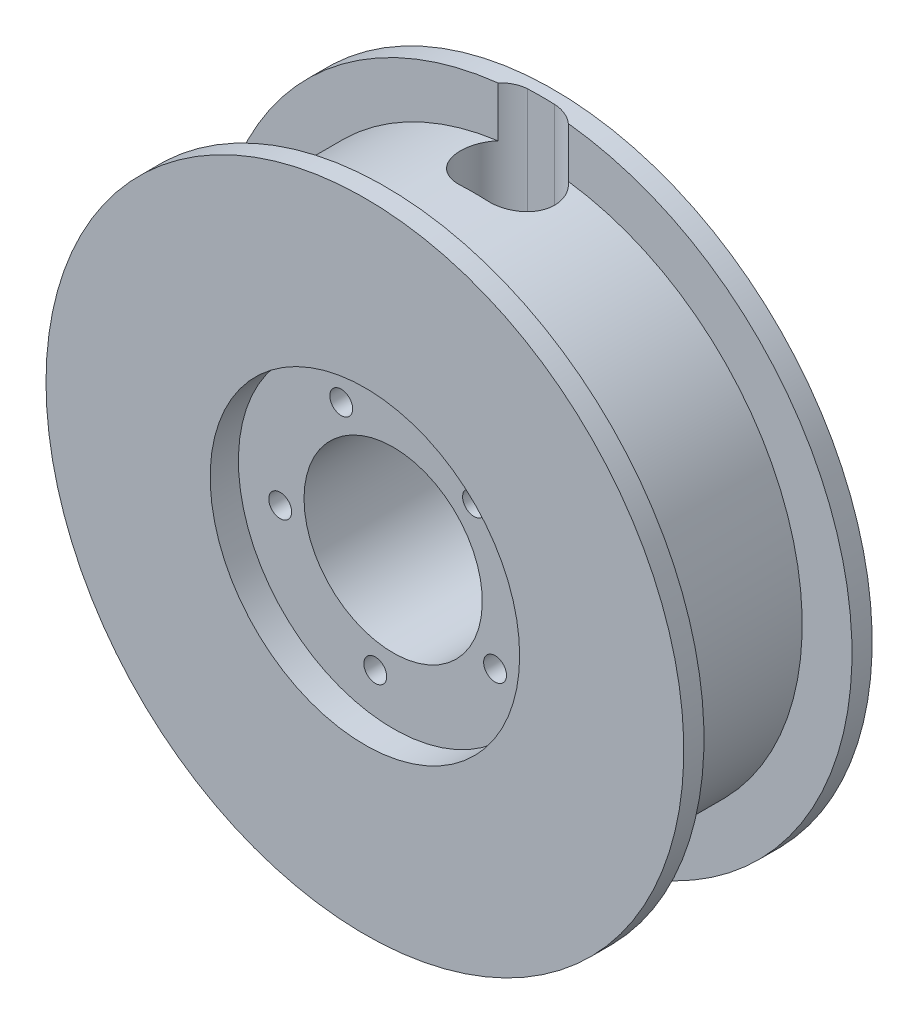
from build123d import *

# Parameters (mm, degrees)
SKIZZE4_R                                   = 11.5
SCHNITT_LINEAR_AUSTRAGEN1_DEPTH             = 2.1
SCHNITT_LINEAR_START                        = -8
SKIZZE5_R                                   = 1
SCHNITT_LINEAR_AUSTRAGEN2_DEPTH             = 1
SCHNITT_LINEAR_AUSTRAGEN3_REACH             = 31.825
SCHNITT_LINEAR_AUSTRAGEN3_DIRECTION_2_DEPTH = 18.575
SKIZZE7_R                                   = 0.85
SCHNITT_LINEAR_AUSTRAGEN4_DEPTH             = 10


with BuildPart() as part:
    # Skizze3 → Rotation1 (revolve)
    with BuildSketch(Plane(origin=(0, 0, 0), x_dir=(0, 0, -1), z_dir=(1, 0, 0))):
        Polygon((-1.5, 4.2), (0, 4.2), (0, 0.5), (11, 0.5), (11, 4.2), (12.5, 4.2), (12.5, -12.875), (-1.5, -12.875), align=None)
    revolve(axis=Axis((0, -19.5, -13), (0, 0, 1)))

    # Skizze4 → Schnitt-Linear austragen1 (cut)
    with BuildSketch(Plane.XY.offset(1.5)):
        with Locations((0, -19.5)):
            Circle(SKIZZE4_R)
    extrude(amount=-SCHNITT_LINEAR_AUSTRAGEN1_DEPTH, mode=Mode.SUBTRACT)

    # Skizze5 → Schnitt-Linear austragen2 (cut)
    with BuildSketch(Plane.XY.offset(1.5).offset(SCHNITT_LINEAR_START)):
        with Locations((6.01040764, -13.48959236)):
            Circle(SKIZZE5_R)
        with Locations((7.573555456, -23.358919248)):
            Circle(SKIZZE5_R)
        with Locations((-1.329692953, -27.895350895)):
            Circle(SKIZZE5_R)
        with Locations((-8.395350895, -20.829692953)):
            Circle(SKIZZE5_R)
        with Locations((-3.858919248, -11.926444544)):
            Circle(SKIZZE5_R)
    extrude(amount=-SCHNITT_LINEAR_AUSTRAGEN2_DEPTH, mode=Mode.SUBTRACT)

    # Skizze6 → Schnitt-Linear austragen3 (cut, up to next)
    with BuildSketch(Plane(origin=(9.01325694, -13.375, -16.436641525), x_dir=(1, 0, 0), z_dir=(0, 1, 0)), mode=Mode.PRIVATE) as schnitt_linear_austragen3_sk1:
        with BuildLine():
            Line((-10.01325694, -4.836641525), (-8.01325694, -4.836641525))
            ThreePointArc((-8.01325694, -4.836641525), (-5.51325694, -7.336641525), (-8.01325694, -9.836641525))
            Line((-8.01325694, -9.836641525), (-10.01325694, -9.836641525))
            ThreePointArc((-10.01325694, -9.836641525), (-12.51325694, -7.336641525), (-10.01325694, -4.836641525))
        make_face()
    schnitt_linear_austragen3_tool1 = extrude(schnitt_linear_austragen3_sk1.sketch, amount=-SCHNITT_LINEAR_AUSTRAGEN3_REACH, mode=Mode.PRIVATE) & part.part
    add(schnitt_linear_austragen3_tool1.solids().sort_by_distance((0, -13.375, -9.1))[0], mode=Mode.SUBTRACT)
    add(schnitt_linear_austragen3_tool1.solids().sort_by_distance((0, -13.375, -9.1))[1], mode=Mode.SUBTRACT)

    # Skizze6 → Schnitt-Linear austragen3 direction 2 (cut)
    with BuildSketch(Plane(origin=(9.01325694, -13.375, -16.436641525), x_dir=(1, 0, 0), z_dir=(0, 1, 0))):
        with BuildLine():
            Line((-10.01325694, -4.836641525), (-8.01325694, -4.836641525))
            ThreePointArc((-8.01325694, -4.836641525), (-5.51325694, -7.336641525), (-8.01325694, -9.836641525))
            Line((-8.01325694, -9.836641525), (-10.01325694, -9.836641525))
            ThreePointArc((-10.01325694, -9.836641525), (-12.51325694, -7.336641525), (-10.01325694, -4.836641525))
        make_face()
    extrude(amount=SCHNITT_LINEAR_AUSTRAGEN3_DIRECTION_2_DEPTH, mode=Mode.SUBTRACT)

    # Skizze7 → Schnitt-Linear austragen4 (cut)
    with BuildSketch(Plane.XY.offset(1.5)):
        with Locations((-3.858919248, -11.926444544)):
            Circle(SKIZZE7_R)
        with Locations((6.01040764, -13.48959236)):
            Circle(SKIZZE7_R)
        with Locations((7.573555456, -23.358919248)):
            Circle(SKIZZE7_R)
        with Locations((-1.329692953, -27.895350895)):
            Circle(SKIZZE7_R)
        with Locations((-8.395350895, -20.829692953)):
            Circle(SKIZZE7_R)
    extrude(amount=-SCHNITT_LINEAR_AUSTRAGEN4_DEPTH, mode=Mode.SUBTRACT)


solid = part.part
